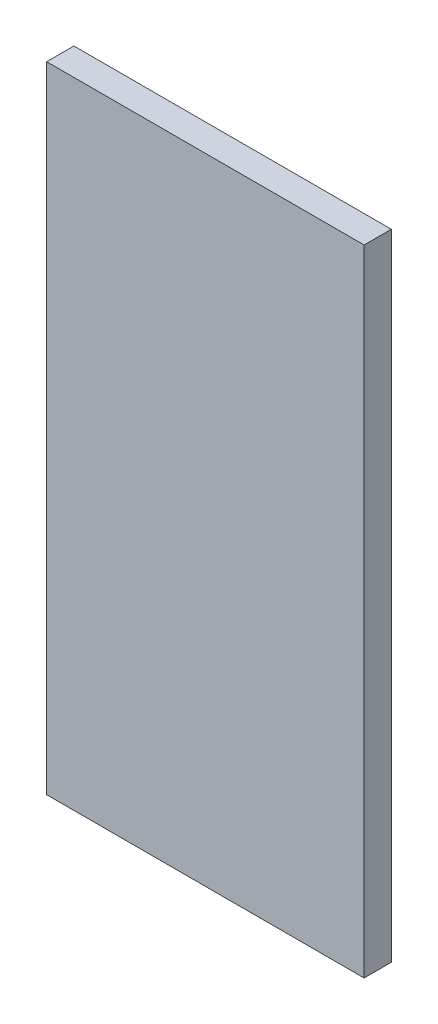
from build123d import *

# Parameters (mm, degrees)
ESQUISSE1_W        = 35
ESQUISSE1_H        = 70
BOSS_EXTRU_1_DEPTH = 3


with BuildPart() as part:
    # Esquisse1 → Boss.-Extru.1 (new body)
    with BuildSketch(Plane.XY):
        with Locations((17.5, -35)):
            Rectangle(ESQUISSE1_W, ESQUISSE1_H)
    extrude(amount=BOSS_EXTRU_1_DEPTH)


solid = part.part
